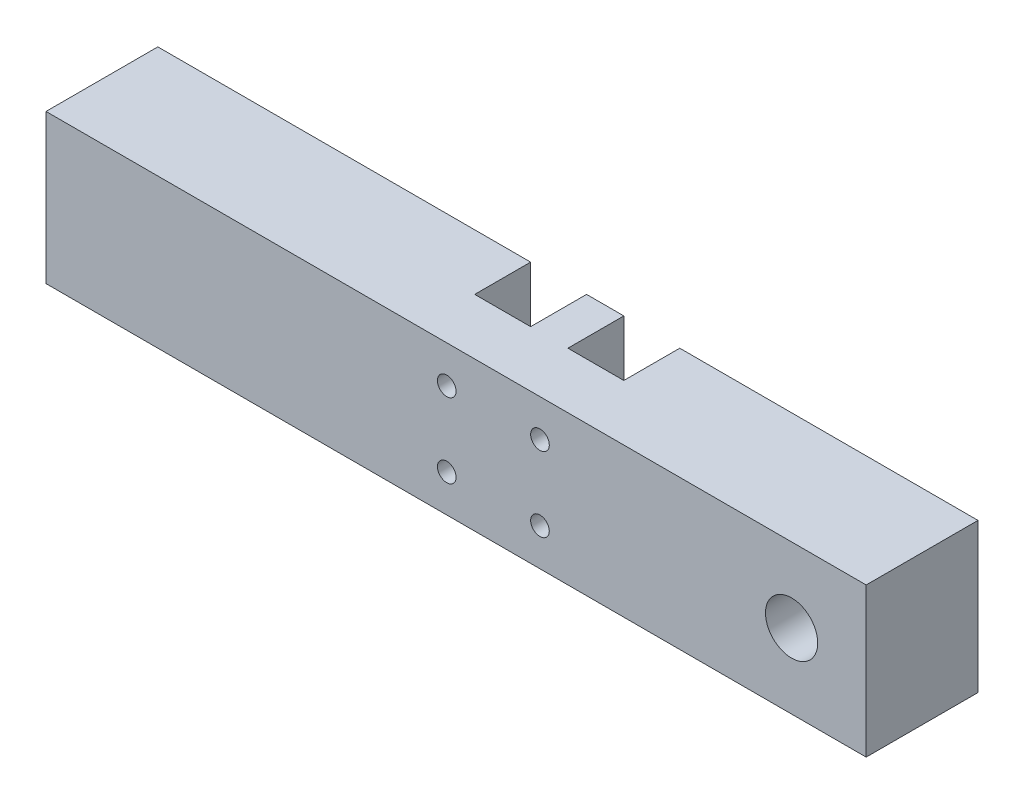
from build123d import *

# Parameters (mm, degrees)
SKETCH1_W           = 220
SKETCH1_H           = 40
BOSS_EXTRUDE1_DEPTH = 30
SKETCH2_R           = 10
CUT_EXTRUDE1_DEPTH  = 7
CUT_EXTRUDE2_START  = -30
SKETCH3_R           = 7
CUT_EXTRUDE2_DEPTH  = 23
SKETCH4_W           = 15
SKETCH4_H           = 40
CUT_EXTRUDE3_DEPTH  = 15
CUT_EXTRUDE4_START  = -30
SKETCH5_R           = 2.5
CUT_EXTRUDE4_DEPTH  = 15


with BuildPart() as part:
    # Sketch1 → Boss-Extrude1 (new body)
    with BuildSketch(Plane.XY):
        Rectangle(SKETCH1_W, SKETCH1_H)
    extrude(amount=BOSS_EXTRUDE1_DEPTH)

    # Sketch2 → Cut-Extrude1 (cut)
    with BuildSketch(Plane.XY):
        with Locations((90, 0)):
            Circle(SKETCH2_R)
    extrude(amount=CUT_EXTRUDE1_DEPTH, mode=Mode.SUBTRACT)

    # Sketch3 → Cut-Extrude2 (cut)
    with BuildSketch(Plane(origin=(0, 0, 0), x_dir=(-1, 0, 0), z_dir=(0, 0, -1)).offset(CUT_EXTRUDE2_START)):
        with Locations((-90, 0)):
            Circle(SKETCH3_R)
    extrude(amount=CUT_EXTRUDE2_DEPTH, mode=Mode.SUBTRACT)

    # Sketch4 → Cut-Extrude3 (cut)
    with BuildSketch(Plane(origin=(0, 0, 0), x_dir=(-1, 0, 0), z_dir=(0, 0, -1))):
        with Locations((-22.5, 0)):
            Rectangle(SKETCH4_W, SKETCH4_H)
        with Locations((2.5, 0)):
            Rectangle(SKETCH4_W, SKETCH4_H)
    extrude(amount=-CUT_EXTRUDE3_DEPTH, mode=Mode.SUBTRACT)

    # Sketch5 → Cut-Extrude4 (cut)
    with BuildSketch(Plane(origin=(0, 0, 0), x_dir=(-1, 0, 0), z_dir=(0, 0, -1)).offset(CUT_EXTRUDE4_START)):
        with Locations((-22.5, 10)):
            Circle(SKETCH5_R)
        with Locations((-22.5, -10)):
            Circle(SKETCH5_R)
        with Locations((2.5, -10)):
            Circle(SKETCH5_R)
        with Locations((2.5, 10)):
            Circle(SKETCH5_R)
    extrude(amount=CUT_EXTRUDE4_DEPTH, mode=Mode.SUBTRACT)


solid = part.part
